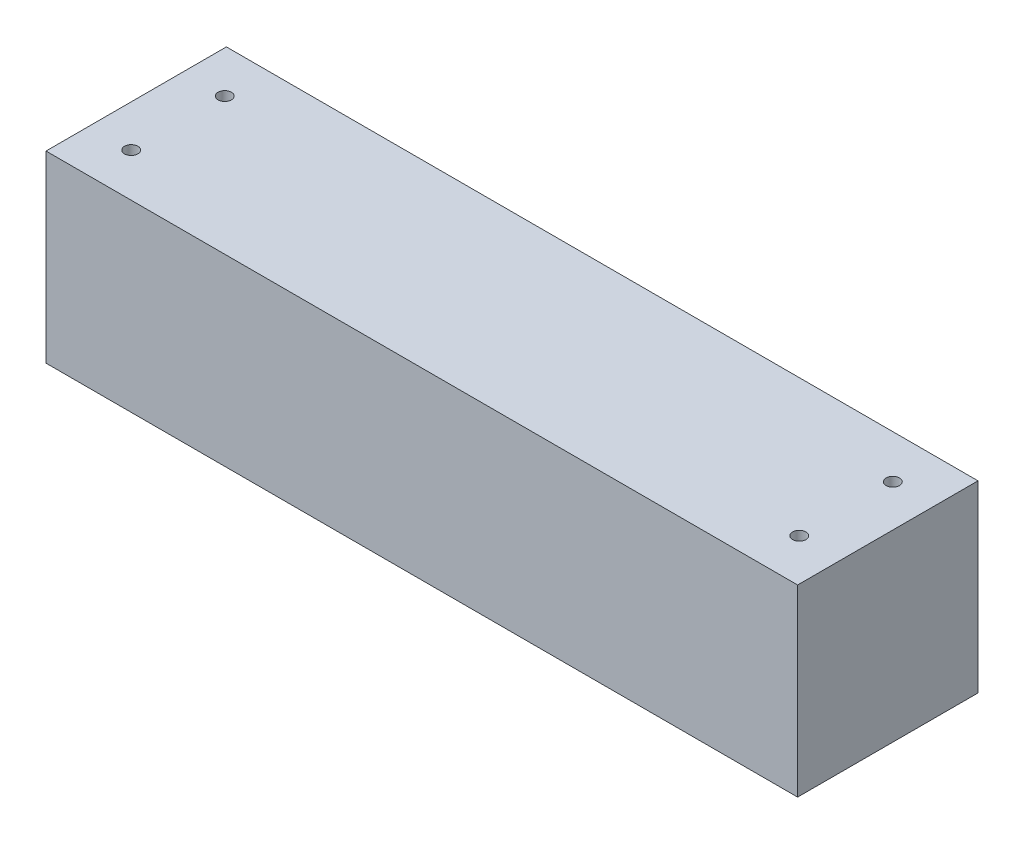
from build123d import *

# Parameters (mm, degrees)
SKETCH1_W           = 225
SKETCH1_H           = 55
BOSS_EXTRUDE1_DEPTH = 54
SHELL1_T            = -4
SKETCH2_R           = 2
CUT_EXTRUDE1_DEPTH  = 10


with BuildPart() as part:
    # Sketch1 → Boss-Extrude1 (new body)
    with BuildSketch(Plane.XY):
        with Locations((112.5, -27.5)):
            Rectangle(SKETCH1_W, SKETCH1_H)
    extrude(amount=BOSS_EXTRUDE1_DEPTH)

    # Shell1
    shell1_openings = [part.faces().sort_by_distance(p)[0] for p in [
        (0, -27.5, 27),
    ]]
    offset(amount=SHELL1_T, openings=shell1_openings, kind=Kind.INTERSECTION)

    # Sketch2 → Cut-Extrude1 (cut)
    with BuildSketch(Plane(origin=(0, 0, 0), x_dir=(1, 0, 0), z_dir=(0, 1, 0))):
        with Locations((12.5, -12.998097245)):
            Circle(SKETCH2_R)
        with Locations((212.5, -12.998097245)):
            Circle(SKETCH2_R)
        with Locations((212.5, -41.001902755)):
            Circle(SKETCH2_R)
        with Locations((12.5, -41.001902755)):
            Circle(SKETCH2_R)
    extrude(amount=-CUT_EXTRUDE1_DEPTH, mode=Mode.SUBTRACT)


solid = part.part
